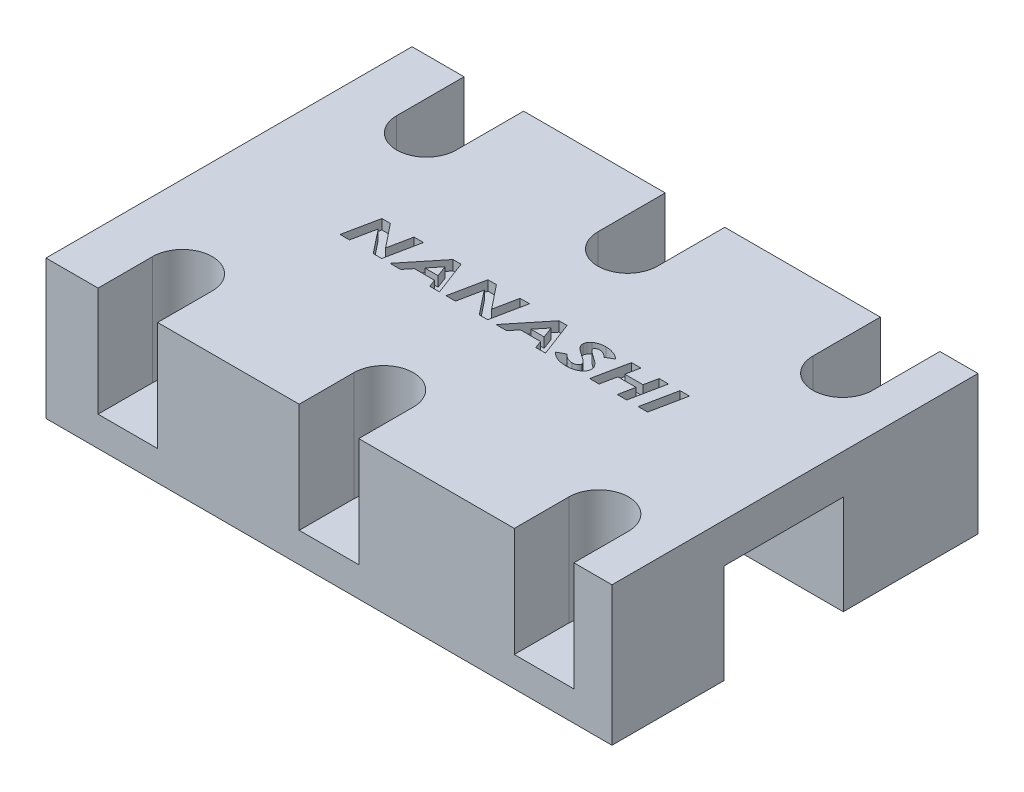
from build123d import *

# Parameters (mm, degrees)
SKETCH2_W             = 57
SKETCH2_H             = 11.291481334
BOSS_EXTRUDE2_DEPTH   = 10.000002
SKETCH2_H_2           = 13.568518663
BOSS_EXTRUDE2_2_DEPTH = 10.000002
SKETCH5_W             = 57
SKETCH5_H             = 13.568518663
SKETCH5_H_2           = 11.291481334
BOSS_EXTRUDE7_DEPTH   = 4
SKETCH13_W            = 57
SKETCH13_H            = 4
BOSS_EXTRUDE8_DEPTH   = 12
SKETCH15_R            = 1.45
CUT_EXTRUDE1_DEPTH    = 15.000002277
CUT_EXTRUDE3_DEPTH    = 11
CUT_EXTRUDE4_DEPTH    = 1


with BuildPart() as part:
    # Sketch2 → Boss-Extrude2 (new body)
    with BuildSketch(Plane(origin=(0, 54.653980571, 0), x_dir=(1, 0, 0), z_dir=(0, 1, 0))):
        with Locations((28.561559826, -65.997629133)):
            Rectangle(SKETCH2_W, SKETCH2_H)
    extrude(amount=BOSS_EXTRUDE2_DEPTH)



with BuildPart() as body_2:
    # Sketch2 → Boss-Extrude2 2 (new body)
    with BuildSketch(Plane(origin=(0, 54.653980571, 0), x_dir=(1, 0, 0), z_dir=(0, 1, 0))):
        with Locations((28.561559826, -41.567629131)):
            Rectangle(SKETCH2_W, SKETCH2_H_2)
    extrude(amount=BOSS_EXTRUDE2_2_DEPTH)


with BuildPart() as part_1:
    add(part.part)

    add(body_2.part)  # Boss-Extrude7 merges body 2
    # Sketch5 → Boss-Extrude7 (add)
    with BuildSketch(Plane(origin=(0, 64.653982848, 0), x_dir=(1, 0, 0), z_dir=(0, 1, 0))):
        with Locations((28.561559826, -41.567629131)):
            Rectangle(SKETCH5_W, SKETCH5_H)
        with Locations((28.561559826, -65.997629133)):
            Rectangle(SKETCH5_W, SKETCH5_H_2)
    extrude(amount=BOSS_EXTRUDE7_DEPTH)

    # Sketch13 → Boss-Extrude8 (add)
    with BuildSketch(Plane.XY.offset(48.351888463)):
        with Locations((28.561559826, 66.653982848)):
            Rectangle(SKETCH13_W, SKETCH13_H)
    extrude(amount=BOSS_EXTRUDE8_DEPTH)

    # Sketch15 → Cut-Extrude1 (cut, through all)
    with BuildSketch(Plane(origin=(0, 68.653982848, 0), x_dir=(1, 0, 0), z_dir=(0, 1, 0))):
        with Locations((28.561559826, -41.5683698)):
            Circle(SKETCH15_R)
        with Locations((50.223970064, -41.5683698)):
            Circle(SKETCH15_R)
        with Locations((8.304214833, -41.5683698)):
            Circle(SKETCH15_R)
        with Locations((8.304214833, -66.1433698)):
            Circle(SKETCH15_R)
        with Locations((28.561559826, -66.1433698)):
            Circle(SKETCH15_R)
        with Locations((50.223970064, -66.1433698)):
            Circle(SKETCH15_R)
    extrude(amount=-CUT_EXTRUDE1_DEPTH, mode=Mode.SUBTRACT)

    # Sketch16 → Cut-Extrude3 (cut)
    with BuildSketch(Plane(origin=(0, 68.653982848, 0), x_dir=(1, 0, 0), z_dir=(0, 1, 0))):
        with BuildLine():
            Line((5.304214833, -41.5683698), (5.304214833, -34.7833698))
            Line((5.304214833, -34.7833698), (11.304214833, -34.7833698))
            Line((11.304214833, -34.7833698), (11.304214833, -41.5683698))
            ThreePointArc((11.304214833, -41.5683698), (8.304214833, -44.5683698), (5.304214833, -41.5683698))
        make_face()
        with BuildLine():
            Line((25.561559826, -41.5683698), (25.561559826, -34.7833698))
            Line((25.561559826, -34.7833698), (31.561559826, -34.7833698))
            Line((31.561559826, -34.7833698), (31.561559826, -41.5683698))
            ThreePointArc((31.561559826, -41.5683698), (28.561559826, -44.5683698), (25.561559826, -41.5683698))
        make_face()
        with BuildLine():
            Line((47.223970064, -41.5683698), (47.223970064, -34.7833698))
            Line((47.223970064, -34.7833698), (53.223970064, -34.7833698))
            Line((53.223970064, -34.7833698), (53.223970064, -41.5683698))
            ThreePointArc((53.223970064, -41.5683698), (50.223970064, -44.5683698), (47.223970064, -41.5683698))
        make_face()
        with BuildLine():
            Line((47.223970064, -66.1433698), (47.223970064, -71.6433698))
            Line((47.223970064, -71.6433698), (53.223970064, -71.6433698))
            Line((53.223970064, -71.6433698), (53.223970064, -66.1433698))
            ThreePointArc((53.223970064, -66.1433698), (50.223970064, -63.1433698), (47.223970064, -66.1433698))
        make_face()
        with BuildLine():
            Line((25.561559826, -66.1433698), (25.561559826, -71.6433698))
            Line((25.561559826, -71.6433698), (31.561559826, -71.6433698))
            Line((31.561559826, -71.6433698), (31.561559826, -66.1433698))
            ThreePointArc((31.561559826, -66.1433698), (28.561559826, -63.1433698), (25.561559826, -66.1433698))
        make_face()
        with BuildLine():
            Line((5.304214833, -66.1433698), (5.304214833, -71.6433698))
            Line((5.304214833, -71.6433698), (11.304214833, -71.6433698))
            Line((11.304214833, -71.6433698), (11.304214833, -66.1433698))
            ThreePointArc((11.304214833, -66.1433698), (8.304214833, -63.1433698), (5.304214833, -66.1433698))
        make_face()
    extrude(amount=-CUT_EXTRUDE3_DEPTH, mode=Mode.SUBTRACT)

    # Sketch17 → Cut-Extrude4 (cut)
    with BuildSketch(Plane(origin=(0, 68.653982848, 0), x_dir=(1, 0, 0), z_dir=(0, 1, 0))):
        Polygon((13.531158207, -51.28443017), (14.383021188, -51.28443017), (16.280957887, -53.664037542), (16.766835291, -51.28443017), (17.717556444, -51.28443017), (17.005216701, -54.78443017), (16.158261573, -54.78443017), (14.2547159, -52.378881292), (13.763930643, -54.78443017), (12.813209489, -54.78443017), align=None)
        Polygon((20.681198271, -51.28443017), (21.502913015, -51.28443017), (22.828033207, -54.78443017), (21.855577278, -54.78443017), (21.566715098, -54.021609657), (19.536967502, -54.021609657), (18.919279201, -54.78443017), (17.847263977, -54.78443017), align=None)
        Polygon((21.345861733, -53.438276324), (20.920280803, -52.312975843), (20.009523592, -53.438276324), align=None, mode=Mode.SUBTRACT)
        Polygon((24.210645387, -51.28443017), (25.062508368, -51.28443017), (26.960445066, -53.664037542), (27.44632247, -51.28443017), (28.397043624, -51.28443017), (27.68470388, -54.78443017), (26.837748752, -54.78443017), (24.934203079, -52.378881292), (24.443417823, -54.78443017), (23.492696669, -54.78443017), align=None)
        Polygon((31.360685451, -51.28443017), (32.182400194, -51.28443017), (33.507520387, -54.78443017), (32.535064457, -54.78443017), (32.246202278, -54.021609657), (30.216454682, -54.021609657), (29.59876638, -54.78443017), (28.526751156, -54.78443017), align=None)
        Polygon((32.025348912, -53.438276324), (31.599767983, -52.312975843), (30.689010771, -53.438276324), align=None, mode=Mode.SUBTRACT)
        with BuildLine():
            Line((37.56350997, -51.771008696), (36.825929842, -52.195187382))
            add(Edge.make_bspline(
                [(36.825929842, -52.195187382), (36.788703764, -52.16221976), (36.716647854, -52.098406645), (36.605479993, -52.013620356), (36.497105617, -51.940328031), (36.389412487, -51.882305104), (36.284357996, -51.835765814), (36.180839981, -51.802471078), (36.078896044, -51.781757871), (36.011316132, -51.779247389), (35.978273592, -51.778019914)],
                knots=[0, 0, 0, 0, 0.00014913, 0.00028866, 0.00041914, 0.00054118, 0.000655155, 0.000763359, 0.0008669, 0.00096596, 0.00096596, 0.00096596, 0.00096596], degree=3))
            add(Edge.make_bspline(
                [(35.978273592, -51.778019914), (35.947131896, -51.778934737), (35.887313558, -51.780691969), (35.801514948, -51.794814513), (35.723731297, -51.818105489), (35.656241835, -51.851771075), (35.599916189, -51.890523782), (35.558527115, -51.934755283), (35.530842048, -51.983443109), (35.528103994, -52.018641604), (35.526751156, -52.036032734)],
                knots=[0, 0, 0, 0, 9.3378e-05, 0.000179365, 0.000260089, 0.000335969, 0.000404839, 0.000463888, 0.000516886, 0.000568646, 0.000568646, 0.000568646, 0.000568646], degree=3))
            add(Edge.make_bspline(
                [(35.526751156, -52.036032734), (35.528540554, -52.053036087), (35.532369218, -52.089417108), (35.55589538, -52.144285495), (35.594512721, -52.200405446), (35.637805588, -52.249804414), (35.686613358, -52.293905109), (35.7383202, -52.338169409), (35.806070665, -52.390203092), (35.888381276, -52.452074093), (35.985395787, -52.523430933), (36.098126222, -52.60306145), (36.224636916, -52.693235022), (36.314936832, -52.755072158), (36.362488335, -52.787635298)],
                knots=[0, 0, 0, 0, 5.1067e-05, 0.000109264, 0.000176546, 0.000255034, 0.000305641, 0.00037378, 0.000459193, 0.000561838, 0.000682718, 0.000820459, 0.000975888, 0.001148781, 0.001148781, 0.001148781, 0.001148781], degree=3))
            add(Edge.make_bspline(
                [(36.362488335, -52.787635298), (36.388017094, -52.805084746), (36.436940133, -52.83852468), (36.506151638, -52.887662219), (36.568590745, -52.932482782), (36.624297964, -52.973274679), (36.673138532, -53.01022032), (36.715232778, -53.043148285), (36.750459259, -53.071720781), (36.771061984, -53.089990052), (36.780356925, -53.098232254)],
                knots=[0, 0, 0, 0, 9.2766e-05, 0.000177775, 0.000254633, 0.000323347, 0.000384906, 0.000438343, 0.000483678, 0.000520943, 0.000520943, 0.000520943, 0.000520943], degree=3))
            add(Edge.make_bspline(
                [(36.780356925, -53.098232254), (36.817946592, -53.132605113), (36.889704623, -53.198222315), (36.985433718, -53.298915261), (37.064089104, -53.396539853), (37.126339419, -53.491568446), (37.173547423, -53.585194686), (37.206933748, -53.679115261), (37.228477551, -53.77383361), (37.230753138, -53.837805534), (37.231879361, -53.869466228)],
                knots=[0, 0, 0, 0, 0.000152777, 0.000291649, 0.000416366, 0.000528381, 0.000631853, 0.000730092, 0.000826903, 0.000921764, 0.000921764, 0.000921764, 0.000921764], degree=3))
            add(Edge.make_bspline(
                [(37.231879361, -53.869466228), (37.230569446, -53.90439735), (37.227977881, -53.973505881), (37.206091968, -54.074820567), (37.170838162, -54.171498014), (37.121601737, -54.264030443), (37.058083571, -54.351928519), (36.979677102, -54.434679502), (36.888973191, -54.514646832), (36.78387576, -54.587599663), (36.669284464, -54.655675351), (36.544936647, -54.713517642), (36.413399564, -54.763721451), (36.273566317, -54.804062674), (36.125956457, -54.835650791), (35.97060524, -54.857503999), (35.807486824, -54.872316298), (35.695989845, -54.873544977), (35.638930643, -54.87417376)],
                knots=[0, 0, 0, 0, 0.000104702, 0.000207145, 0.000309396, 0.000412585, 0.000520578, 0.000633683, 0.000753921, 0.000882698, 0.001016893, 0.001153324, 0.001293566, 0.001438894, 0.001589472, 0.001746036, 0.0019093, 0.002080425, 0.002080425, 0.002080425, 0.002080425], degree=3))
            add(Edge.make_bspline(
                [(35.638930643, -54.87417376), (35.594983, -54.873587522), (35.508189017, -54.872429737), (35.379511226, -54.864654779), (35.254086149, -54.851503114), (35.131790796, -54.83235781), (35.012487177, -54.808527625), (34.896060764, -54.780052741), (34.782797203, -54.745574282), (34.672740482, -54.705382222), (34.565299859, -54.660826541), (34.461245619, -54.610034142), (34.360407253, -54.554039385), (34.262760169, -54.49270996), (34.167825551, -54.427021111), (34.076566273, -54.355068787), (33.988108757, -54.278069648), (33.931904616, -54.223111827), (33.903654201, -54.195487862)],
                knots=[0, 0, 0, 0, 0.000131841, 0.000260378, 0.000386583, 0.000510039, 0.00063159, 0.000751473, 0.000869466, 0.000986572, 0.001102851, 0.001218245, 0.00133374, 0.001448712, 0.001564048, 0.0016799, 0.00179717, 0.001915685, 0.001915685, 0.001915685, 0.001915685], degree=3))
            Line((33.903654201, -54.195487862), (34.673485932, -53.7881361))
            add(Edge.make_bspline(
                [(34.673485932, -53.7881361), (34.711865964, -53.828066833), (34.78667642, -53.905899922), (34.906969353, -54.00865026), (35.029994906, -54.095066402), (35.154610402, -54.167084994), (35.282457703, -54.222178571), (35.412748944, -54.261459925), (35.545415321, -54.286604501), (35.634848114, -54.289427795), (35.679595707, -54.290840427)],
                knots=[0, 0, 0, 0, 0.000166083, 0.000323729, 0.000473701, 0.000616582, 0.000754767, 0.000890286, 0.001024236, 0.001158372, 0.001158372, 0.001158372, 0.001158372], degree=3))
            add(Edge.make_bspline(
                [(35.679595707, -54.290840427), (35.721061972, -54.289619929), (35.801064229, -54.287265181), (35.915685753, -54.265726214), (36.020268086, -54.231518933), (36.099054432, -54.19114543), (36.154195649, -54.152564547), (36.190697209, -54.12320091), (36.221038348, -54.091553075), (36.245450889, -54.058287813), (36.26615125, -54.024537676), (36.27895613, -53.988155225), (36.288063295, -53.950776772), (36.289066423, -53.925144751), (36.289571669, -53.912234657)],
                knots=[0, 0, 0, 0, 0.000124296, 0.000239809, 0.000348449, 0.000453501, 0.000503874, 0.000550196, 0.000593835, 0.000634921, 0.000673882, 0.00071204, 0.00075014, 0.000788804, 0.000788804, 0.000788804, 0.000788804], degree=3))
            add(Edge.make_bspline(
                [(36.289571669, -53.912234657), (36.28815679, -53.891497617), (36.285241504, -53.848769988), (36.262418658, -53.785640743), (36.227110674, -53.722109426), (36.185761267, -53.668878009), (36.140865421, -53.622460314), (36.093470612, -53.5800088), (36.033666981, -53.530124797), (35.960614144, -53.473748069), (35.874958274, -53.409762626), (35.776061146, -53.339300643), (35.664601244, -53.261437832), (35.585706477, -53.207752369), (35.544279201, -53.179562382)],
                knots=[0, 0, 0, 0, 6.2096e-05, 0.000127945, 0.000199177, 0.000279672, 0.000329259, 0.000392787, 0.000470437, 0.000562861, 0.000669572, 0.000791175, 0.000927132, 0.001077456, 0.001077456, 0.001077456, 0.001077456], degree=3))
            add(Edge.make_bspline(
                [(35.544279201, -53.179562382), (35.499976194, -53.149604926), (35.414846053, -53.092040381), (35.29468367, -53.006328416), (35.185940329, -52.927490156), (35.089196012, -52.854051349), (35.004112704, -52.786754294), (34.93084503, -52.724893841), (34.869280123, -52.669236114), (34.834084333, -52.632180819), (34.817917021, -52.615159337)],
                knots=[0, 0, 0, 0, 0.000160436, 0.000308285, 0.000442772, 0.000563367, 0.000672645, 0.000768163, 0.000851029, 0.000921435, 0.000921435, 0.000921435, 0.000921435], degree=3))
            add(Edge.make_bspline(
                [(34.817917021, -52.615159337), (34.799427492, -52.593875531), (34.763523776, -52.552545775), (34.715455284, -52.48868358), (34.675338329, -52.424533461), (34.642121662, -52.360908984), (34.616565265, -52.297225503), (34.598409617, -52.234040807), (34.586303907, -52.171109817), (34.585060643, -52.129101809), (34.584443464, -52.108248279)],
                knots=[0, 0, 0, 0, 8.4566e-05, 0.000164213, 0.000239498, 0.000311308, 0.00037927, 0.000444951, 0.000508351, 0.000570849, 0.000570849, 0.000570849, 0.000570849], degree=3))
            add(Edge.make_bspline(
                [(34.584443464, -52.108248279), (34.585310048, -52.081290765), (34.587042531, -52.027397069), (34.603446268, -51.948174154), (34.6277509, -51.870690252), (34.663574689, -51.795738083), (34.709268696, -51.723055503), (34.764826075, -51.652248069), (34.82983963, -51.583393182), (34.879414664, -51.541504161), (34.904856124, -51.520007093)],
                knots=[0, 0, 0, 0, 8.0778e-05, 0.000161493, 0.000241758, 0.00032393, 0.000409917, 0.000498835, 0.000593559, 0.000693417, 0.000693417, 0.000693417, 0.000693417], degree=3))
            add(Edge.make_bspline(
                [(34.904856124, -51.520007093), (34.93937798, -51.493746211), (35.008770857, -51.440958836), (35.123807431, -51.375380397), (35.24666042, -51.319004134), (35.378758345, -51.273621248), (35.51940113, -51.237675395), (35.669091643, -51.21313366), (35.827183214, -51.197114236), (35.93546404, -51.195508545), (35.990893784, -51.19468658)],
                knots=[0, 0, 0, 0, 0.000130003, 0.000261321, 0.00039623, 0.000535034, 0.000679746, 0.000831202, 0.000989707, 0.001155945, 0.001155945, 0.001155945, 0.001155945], degree=3))
            add(Edge.make_bspline(
                [(35.990893784, -51.19468658), (36.029701059, -51.195016692), (36.106446384, -51.19566952), (36.22033713, -51.203111666), (36.331897035, -51.214244225), (36.441213499, -51.229439494), (36.548158846, -51.249779757), (36.652305344, -51.275326081), (36.754509134, -51.303806512), (36.854030286, -51.33737976), (36.950900875, -51.376320514), (37.045902371, -51.418858785), (37.137958544, -51.466807472), (37.228604877, -51.517786857), (37.31556013, -51.574837034), (37.401008819, -51.635224649), (37.483950485, -51.700416085), (37.536864584, -51.747366419), (37.56350997, -51.771008696)],
                knots=[0, 0, 0, 0, 0.000116405, 0.000230203, 0.000342245, 0.000452702, 0.000561195, 0.000668668, 0.000774316, 0.00087941, 0.000983566, 0.001087431, 0.001191538, 0.00129485, 0.001399282, 0.001503363, 0.001608702, 0.001715551, 0.001715551, 0.001715551, 0.001715551], degree=3))
        make_face()
        Polygon((38.664271188, -51.28443017), (39.61429122, -51.28443017), (39.340152598, -52.630584016), (41.170781605, -52.630584016), (41.44632247, -51.28443017), (42.396342502, -51.28443017), (41.682600515, -54.78443017), (40.731879361, -54.78443017), (41.052292021, -53.21391735), (39.220961893, -53.21391735), (38.900549233, -54.78443017), (37.949828079, -54.78443017), align=None)
        Polygon((43.555296829, -51.28443017), (44.505316861, -51.28443017), (43.791574874, -54.78443017), (42.84085372, -54.78443017), align=None)
    extrude(amount=-CUT_EXTRUDE4_DEPTH, mode=Mode.SUBTRACT)


solid = part_1.part
